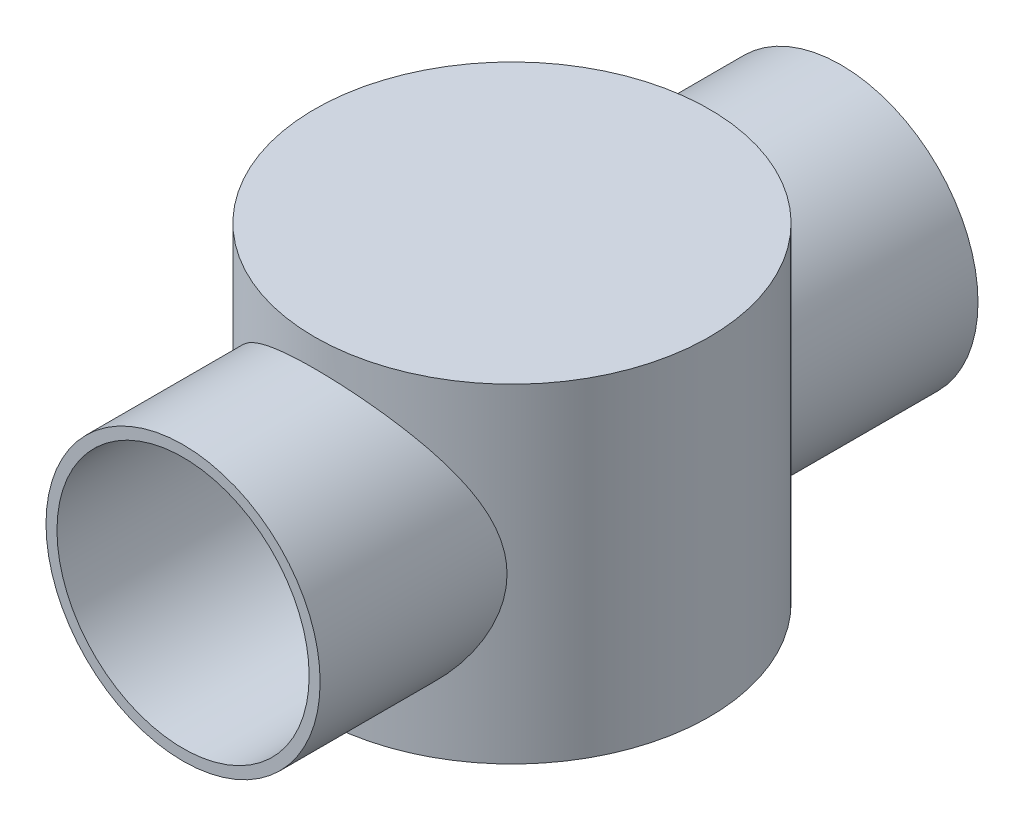
from build123d import *

# Parameters (mm, degrees)
SKETCH1_R                = 18
BOSS_EXTRUDE1_DEPTH      = 30
BOSS_EXTRUDE2_DEPTH      = 30
BOSS_EXTRUDE2_DEPTH_BACK = 30
SKETCH2_R                = 12.5
SKETCH3_R                = 11.5
CUT_EXTRUDE1_DEPTH       = 70.455021572


with BuildPart() as part:
    # Sketch1 → Boss-Extrude1 (new body)
    with BuildSketch(Plane(origin=(0, 0, 0), x_dir=(1, 0, 0), z_dir=(0, 1, 0))):
        Circle(SKETCH1_R)
    extrude(amount=BOSS_EXTRUDE1_DEPTH)

    # Sketch2 → Boss-Extrude2 (add, two sides: drawn at the far end of the back side and taken through both)
    with BuildSketch(Plane.XY.offset(-BOSS_EXTRUDE2_DEPTH_BACK)):
        with Locations((0, 15)):
            Circle(SKETCH2_R)
    extrude(amount=BOSS_EXTRUDE2_DEPTH + BOSS_EXTRUDE2_DEPTH_BACK)

    # Sketch3 → Cut-Extrude1 (cut, through all)
    with BuildSketch(Plane.XY.offset(30)):
        with Locations((0, 15)):
            Circle(SKETCH3_R)
    extrude(amount=-CUT_EXTRUDE1_DEPTH, mode=Mode.SUBTRACT)


solid = part.part
